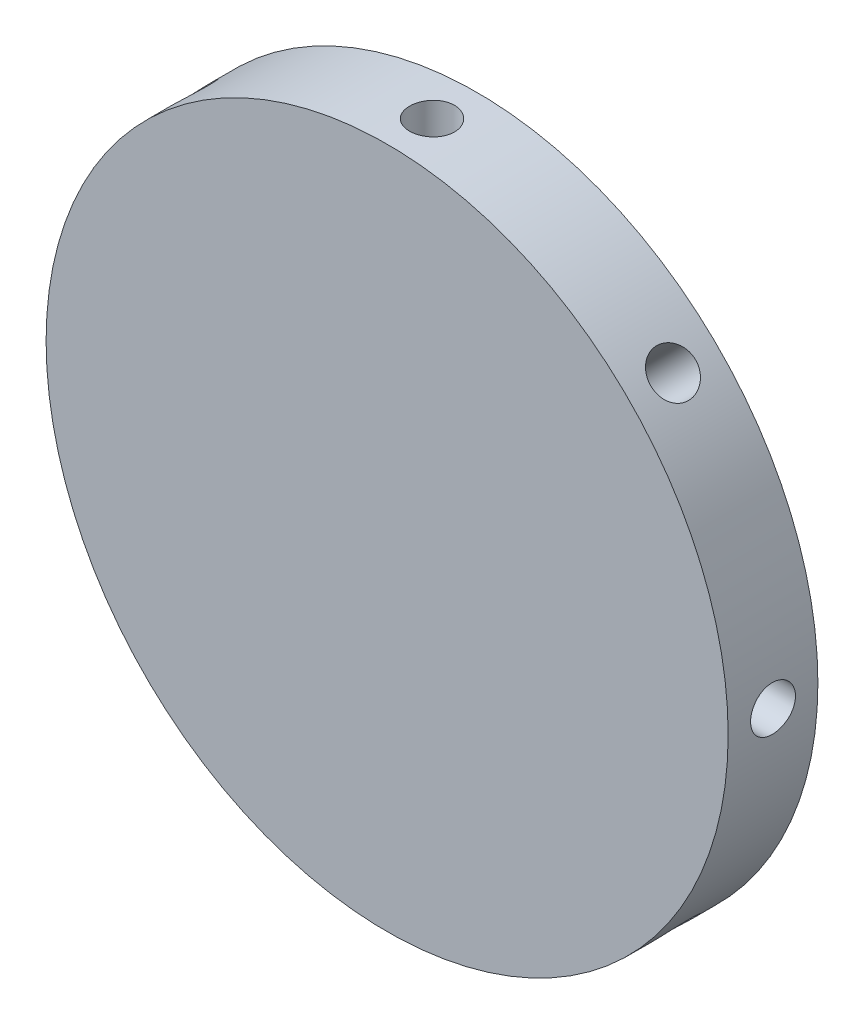
from build123d import *

# Parameters (mm, degrees)
SKETCH1_R           = 38
BOSS_EXTRUDE1_DEPTH = 10
SKETCH2_R           = 2.5
CUT_EXTRUDE1_DEPTH  = 10
CIRPATTERN1_COUNT   = 8


with BuildPart() as part:
    # Sketch1 → Boss-Extrude1 (new body)
    with BuildSketch(Plane.XY):
        Circle(SKETCH1_R)
    extrude(amount=BOSS_EXTRUDE1_DEPTH)

    # Sketch2 → Cut-Extrude1 (cut)
    with BuildSketch(Plane(origin=(0, 38, 0), x_dir=(1, 0, 0), z_dir=(0, 1, 0))):
        with Locations((0, -5)):
            Circle(SKETCH2_R)
    cut_extrude1 = extrude(amount=-CUT_EXTRUDE1_DEPTH, mode=Mode.SUBTRACT)

    # CirPattern1: Cut-Extrude1 ×8 about axis
    cirpattern1_axis = Axis((0, 0, 0), (0, 0, 1))
    for i in range(1, CIRPATTERN1_COUNT):
        add(cut_extrude1.rotate(cirpattern1_axis, i * 360 / CIRPATTERN1_COUNT), mode=Mode.SUBTRACT)


solid = part.part
